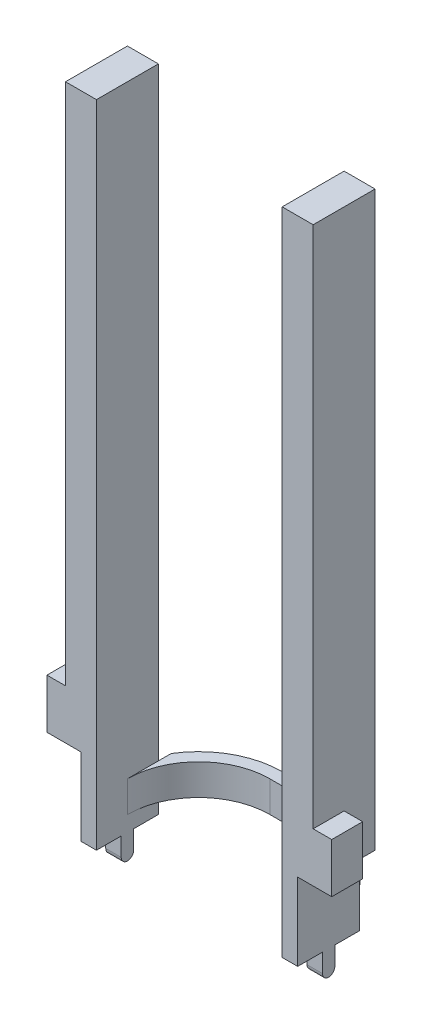
from build123d import *

# Parameters (mm, degrees)
EXTRUDE_1_DEPTH     = 10
SKETCH_3_W          = 10
SKETCH_3_H          = 20
EXTRUDE_2_DEPTH     = 15
EXTRUDE_3_DEPTH     = 10
EXTRUDE_4_DEPTH     = 10
SKETCH_6_W          = 10
SKETCH_6_H          = 20
EXTRUDE_5_DEPTH     = 180
SKETCH_7_W          = 10.379175533
SKETCH_7_H          = 10.878140119
SKETCH_7_W_2        = 7.174479062
SKETCH_7_H_2        = 11.599196825
CUT_EXTRUDE_1_DEPTH = 211
SKETCH_8_W          = 5
SKETCH_8_H          = 20
CUT_EXTRUDE_2_DEPTH = 25
SKETCH_9_W          = 6
SKETCH_9_H          = 16
EXTRUDE_6_DEPTH     = 10


with BuildPart() as part:
    # 草图2 → 凸台-拉伸1 (new body)
    with BuildSketch(Plane(origin=(0, 0, 0), x_dir=(1, 0, 0), z_dir=(0, 1, 0))):
        with BuildLine():
            Line((-7, 23), (7, 23))
            ThreePointArc((7, 23), (23.263455967, 16.263455967), (30, 0))
            Line((30, 0), (34, 0))
            ThreePointArc((34, 0), (26.091883092, 19.091883092), (7, 27))
            Line((7, 27), (-7, 27))
            ThreePointArc((-7, 27), (-26.091883092, 19.091883092), (-34, 0))
            Line((-34, 0), (-30, 0))
            ThreePointArc((-30, 0), (-23.263455967, 16.263455967), (-7, 23))
        make_face()
    extrude(amount=EXTRUDE_1_DEPTH)

    # 草图3 → 凸台-拉伸2 (add, symmetric)
    with BuildSketch(Plane(origin=(0, 10, 0), x_dir=(1, 0, 0), z_dir=(0, 1, 0))):
        with Locations((-35, 0)):
            Rectangle(SKETCH_3_W, SKETCH_3_H)
        with Locations((35, 0)):
            Rectangle(SKETCH_3_W, SKETCH_3_H)
    extrude(amount=EXTRUDE_2_DEPTH, both=True)

    # 草图4 → 凸台-拉伸3 (add)
    with BuildSketch(Plane(origin=(40, 0, 0), x_dir=(0, 0, -1), z_dir=(1, 0, 0))):
        with BuildLine():
            Line((-2, -5), (2, -5))
            Line((2, -5), (2, -11))
            ThreePointArc((2, -11), (0, -13), (-2, -11))
            Line((-2, -11), (-2, -5))
        make_face()
    extrude(amount=-EXTRUDE_3_DEPTH)

    # 草图5 → 凸台-拉伸4 (add)
    with BuildSketch(Plane.ZY.offset(40)):
        with BuildLine():
            Line((-2, -5), (2, -5))
            Line((2, -5), (2, -11))
            ThreePointArc((2, -11), (0, -13), (-2, -11))
            Line((-2, -11), (-2, -5))
        make_face()
    extrude(amount=-EXTRUDE_4_DEPTH)

    # 草图6 → 凸台-拉伸5 (add)
    with BuildSketch(Plane(origin=(0, 25, 0), x_dir=(1, 0, 0), z_dir=(0, 1, 0))):
        with Locations((-35, 0)):
            Rectangle(SKETCH_6_W, SKETCH_6_H)
        with Locations((35, 0)):
            Rectangle(SKETCH_6_W, SKETCH_6_H)
    extrude(amount=EXTRUDE_5_DEPTH)

    # 草图7 → 切除-拉伸1 (cut, through all)
    with BuildSketch(Plane.XZ.offset(5)):
        with Locations((-35.189587767, -15.43907006)):
            Rectangle(SKETCH_7_W, SKETCH_7_H)
        with Locations((33.587239531, -15.799598412)):
            Rectangle(SKETCH_7_W_2, SKETCH_7_H_2)
    extrude(amount=-CUT_EXTRUDE_1_DEPTH, mode=Mode.SUBTRACT)

    # 草图8 → 切除-拉伸2 (cut, symmetric)
    with BuildSketch(Plane.XZ.offset(5)):
        with Locations((-37.5, 0)):
            Rectangle(SKETCH_8_W, SKETCH_8_H)
        with Locations((37.5, 0)):
            Rectangle(SKETCH_8_W, SKETCH_8_H)
    extrude(amount=CUT_EXTRUDE_2_DEPTH, both=True, mode=Mode.SUBTRACT)

    # 草图9 → 凸台-拉伸6 (add)
    with BuildSketch(Plane.XY.offset(10)):
        with Locations((43, 28)):
            Rectangle(SKETCH_9_W, SKETCH_9_H)
        with Locations((-43, 28)):
            Rectangle(SKETCH_9_W, SKETCH_9_H)
    extrude(amount=-EXTRUDE_6_DEPTH)


solid = part.part
